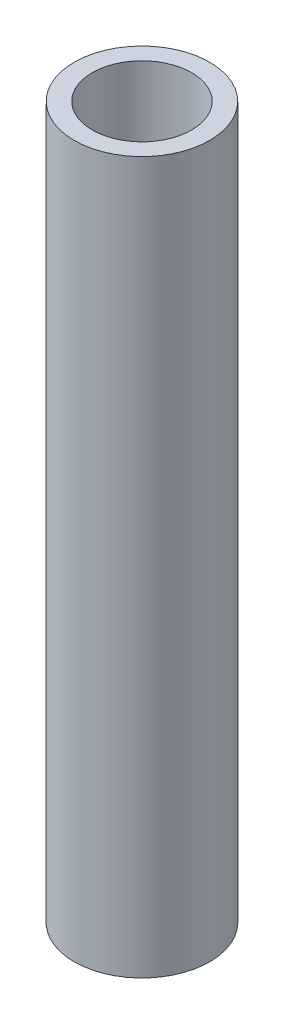
from build123d import *

# Parameters (mm, degrees)
SKETCH1_R           = 15
SKETCH1_R_2         = 11
BOSS_EXTRUDE1_DEPTH = 157.5


with BuildPart() as part:
    # Sketch1 → Boss-Extrude1 (new body)
    with BuildSketch(Plane(origin=(0, 0, 0), x_dir=(1, 0, 0), z_dir=(0, 1, 0))):
        Circle(SKETCH1_R)
        Circle(SKETCH1_R_2, mode=Mode.SUBTRACT)
    extrude(amount=BOSS_EXTRUDE1_DEPTH)


solid = part.part
